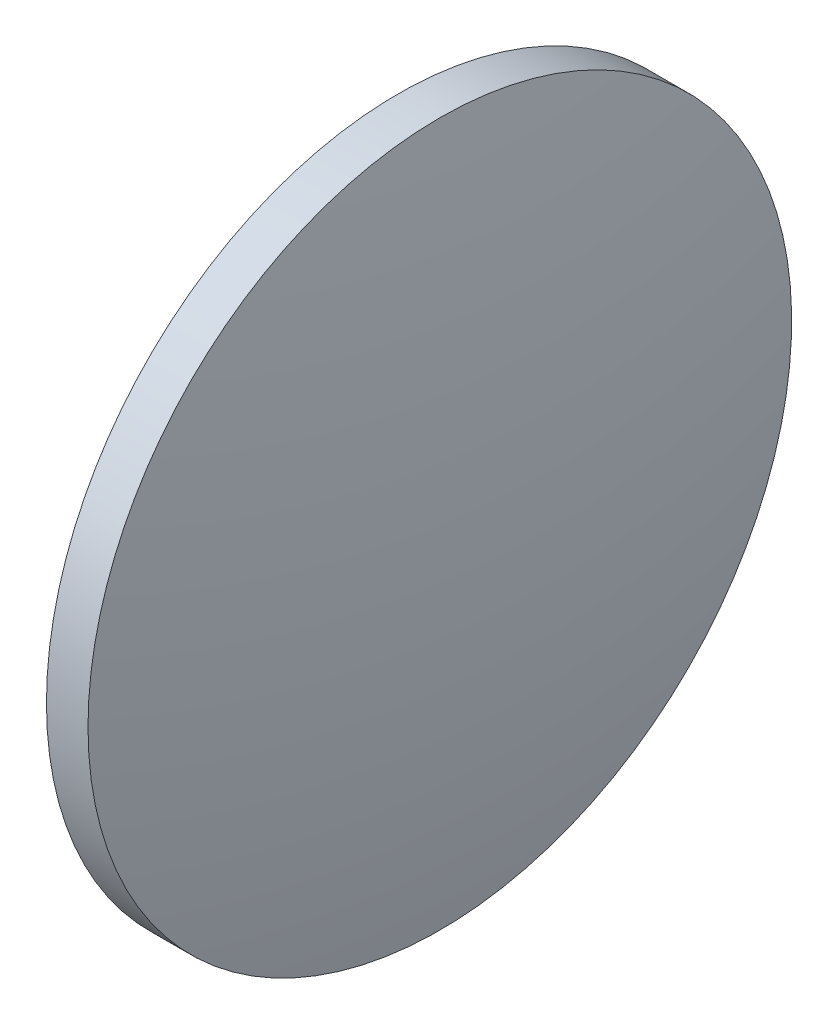
from build123d import *


with BuildPart() as part:
    # 草图1 → 旋转1 (revolve)
    with BuildSketch(Plane.XY):
        with BuildLine():
            Line((232.020820079, 130.467109853), (232.020820079, 155.867109853))
            Line((232.020820079, 155.867109853), (235.020820079, 155.867109853))
            ThreePointArc((235.020820079, 155.867109853), (236.819486822, 143.223676789), (237.420820079, 130.467109853))
            Line((237.420820079, 130.467109853), (232.020820079, 130.467109853))
        make_face()
    revolve(axis=Axis((220.330746457, 130.467109853, 0), (1, 0, 0)))


solid = part.part
